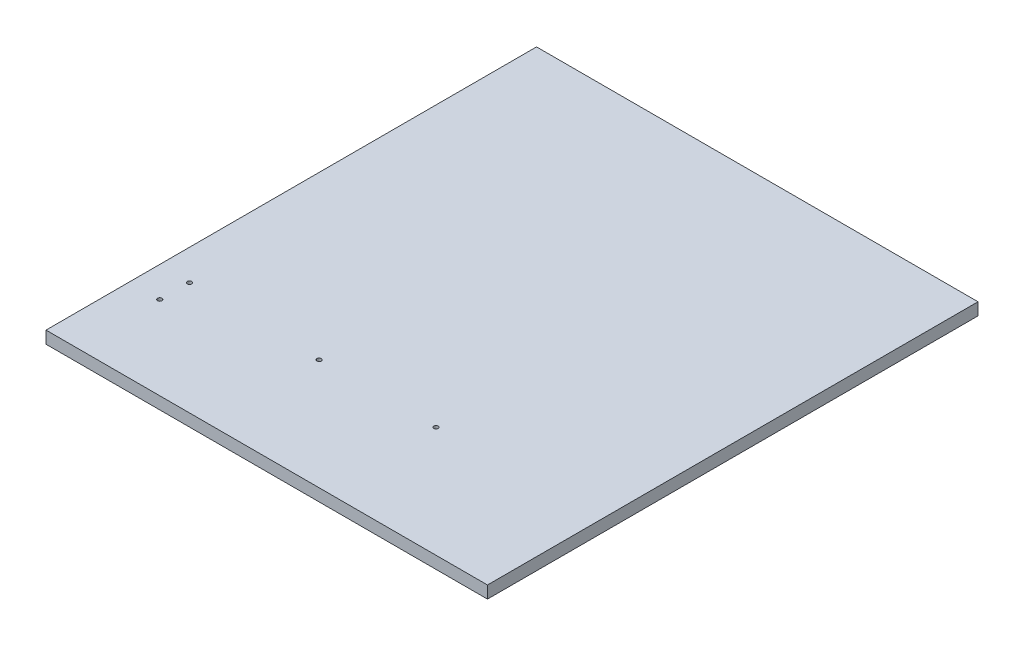
from build123d import *

# Parameters (mm, degrees)
SKETCH1_W             = 228.6
SKETCH1_H             = 254
BOSS_EXTRUDE1_DEPTH   = 6.35
F_4_40_TAPPED_HOLE1_D = 2.2606


with BuildPart() as part:
    # Sketch1 → Boss-Extrude1 (new body)
    with BuildSketch(Plane(origin=(0, 0, 0), x_dir=(1, 0, 0), z_dir=(0, 1, 0))):
        with Locations((114.3, 127)):
            Rectangle(SKETCH1_W, SKETCH1_H)
    extrude(amount=BOSS_EXTRUDE1_DEPTH)

    # #4-40 Tapped Hole1 (through all)
    with Locations(Plane(origin=(0, 6.35, 0), x_dir=(1, 0, 0), z_dir=(0, 1, 0))):
        with Locations((15.735159407, 43.18), (15.875, 58.42), (84.05884141, 57.388437181), (144.561688198, 57.388437181)):
            Hole(F_4_40_TAPPED_HOLE1_D / 2)


solid = part.part
